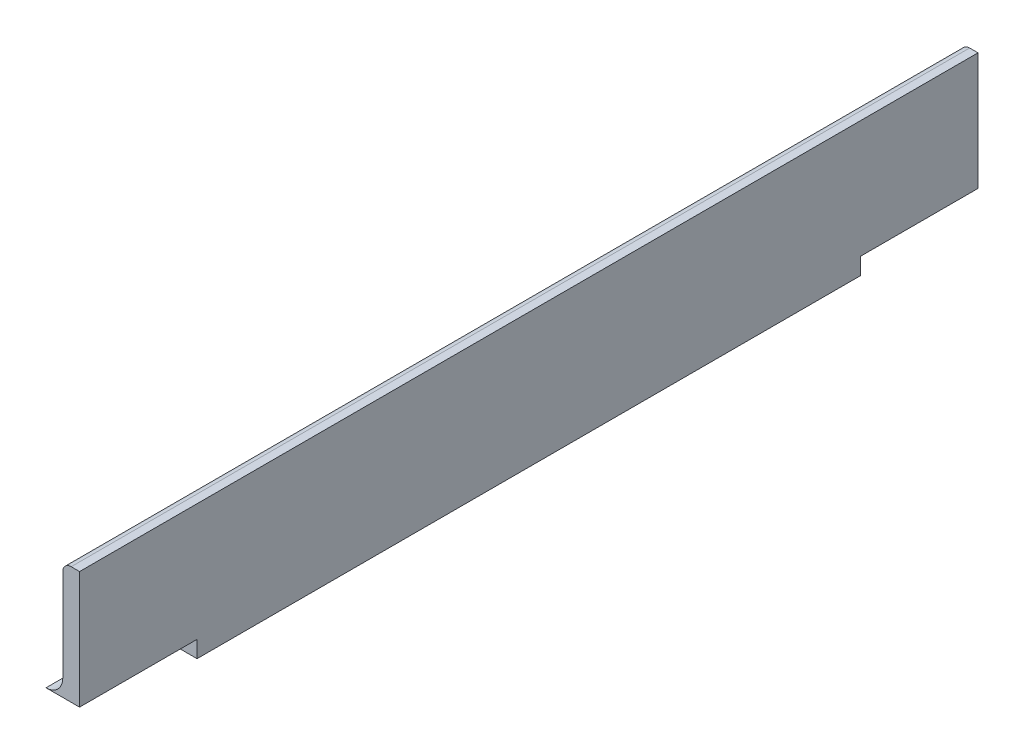
from build123d import *

# Parameters (mm, degrees)
BOSS_EXTRUDE1_DEPTH = 609.6
SKETCH3_W           = 1049.2
SKETCH3_H           = 25.4
CUT_EXTRUDE2_DEPTH  = 30.48
SKETCH6_W           = 25.4
SKETCH6_H           = 3.175
CUT_EXTRUDE4_DEPTH  = 22.23
SKETCH7_W           = 25.4
SKETCH7_H           = 3.175
CUT_EXTRUDE5_DEPTH  = 22.23


with BuildPart() as part:
    # Sketch2 → Boss-Extrude1 (new, symmetric)
    with BuildSketch(Plane.XY):
        with BuildLine():
            Line((-12.7, -12.7), (12.7, -12.7))
            Line((12.7, -12.7), (12.7, 12.7))
            Line((12.7, 12.7), (11.1125, 12.7))
            ThreePointArc((11.1125, 12.7), (9.989967985, 12.235032015), (9.525, 11.1125))
            Line((9.525, 11.1125), (9.525, -6.35))
            ThreePointArc((9.525, -6.35), (8.59506403, -8.59506403), (6.35, -9.525))
            Line((6.35, -9.525), (-11.1125, -9.525))
            ThreePointArc((-11.1125, -9.525), (-12.235032015, -9.989967985), (-12.7, -11.1125))
            Line((-12.7, -11.1125), (-12.7, -12.7))
        make_face()
    extrude(amount=BOSS_EXTRUDE1_DEPTH, both=True)

    # Sketch3 → Cut-Extrude2 (cut)
    with BuildSketch(Plane(origin=(12.7, 0, 0), x_dir=(0, 0, -1), z_dir=(1, 0, 0))):
        with Locations((85, 0)):
            Rectangle(SKETCH3_W, SKETCH3_H)
    extrude(amount=-CUT_EXTRUDE2_DEPTH, mode=Mode.SUBTRACT)

    # Sketch6 → Cut-Extrude4 (cut)
    with BuildSketch(Plane(origin=(0, 0, 439.6), x_dir=(-1, 0, 0), z_dir=(0, 0, -1))):
        with Locations((0, -11.1125)):
            Rectangle(SKETCH6_W, SKETCH6_H)
    extrude(amount=-CUT_EXTRUDE4_DEPTH, mode=Mode.SUBTRACT)

    # Sketch7 → Cut-Extrude5 (cut)
    with BuildSketch(Plane.XY.offset(609.6)):
        with Locations((0, -11.1125)):
            Rectangle(SKETCH7_W, SKETCH7_H)
    extrude(amount=-CUT_EXTRUDE5_DEPTH, mode=Mode.SUBTRACT)


solid = part.part
